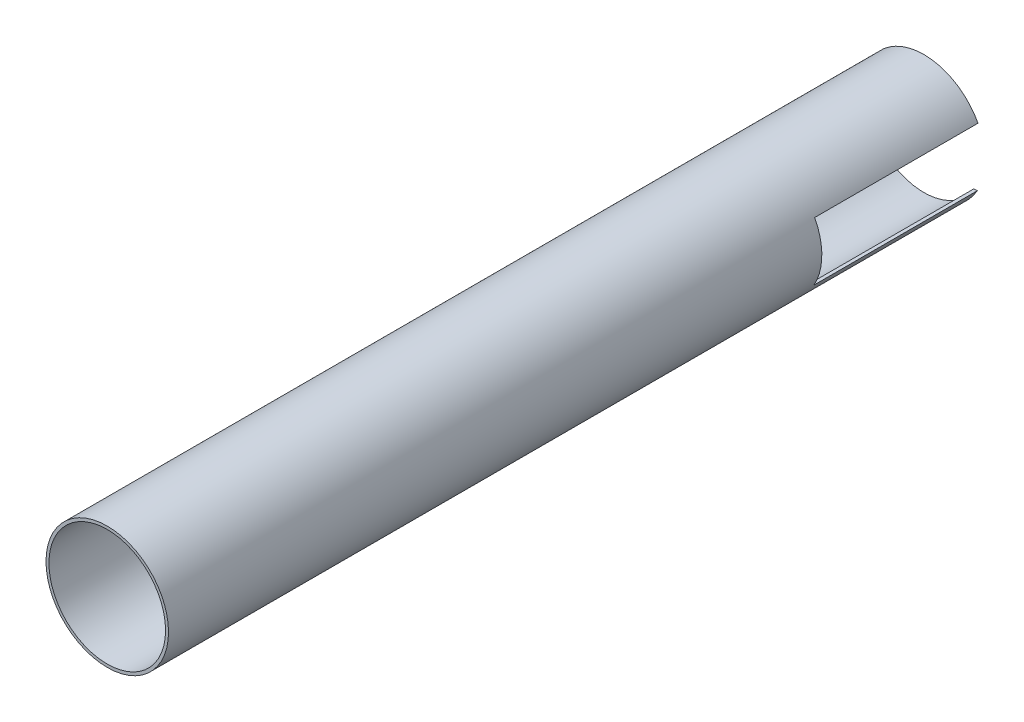
from build123d import *

# Parameters (mm, degrees)
SKETCH2_R           = 37.5
BOSS_EXTRUDE1_DEPTH = 500
SKETCH3_R           = 35.7
CUT_EXTRUDE1_DEPTH  = 500
SKETCH4_W           = 100
SKETCH4_H           = 36
CUT_EXTRUDE2_DEPTH  = 500


with BuildPart() as part:
    # Sketch2 → Boss-Extrude1 (new body)
    with BuildSketch(Plane.XY):
        Circle(SKETCH2_R)
    extrude(amount=BOSS_EXTRUDE1_DEPTH)

    # Sketch3 → Cut-Extrude1 (cut)
    with BuildSketch(Plane.XY.offset(500)):
        Circle(SKETCH3_R)
    extrude(amount=-CUT_EXTRUDE1_DEPTH, mode=Mode.SUBTRACT)

    # Sketch4 → Cut-Extrude2 (cut, symmetric)
    with BuildSketch(Plane(origin=(0, 0, 0), x_dir=(0, 0, -1), z_dir=(1, 0, 0))):
        with Locations((-50, -0.380488828)):
            Rectangle(SKETCH4_W, SKETCH4_H)
    extrude(amount=CUT_EXTRUDE2_DEPTH, both=True, mode=Mode.SUBTRACT)


solid = part.part
